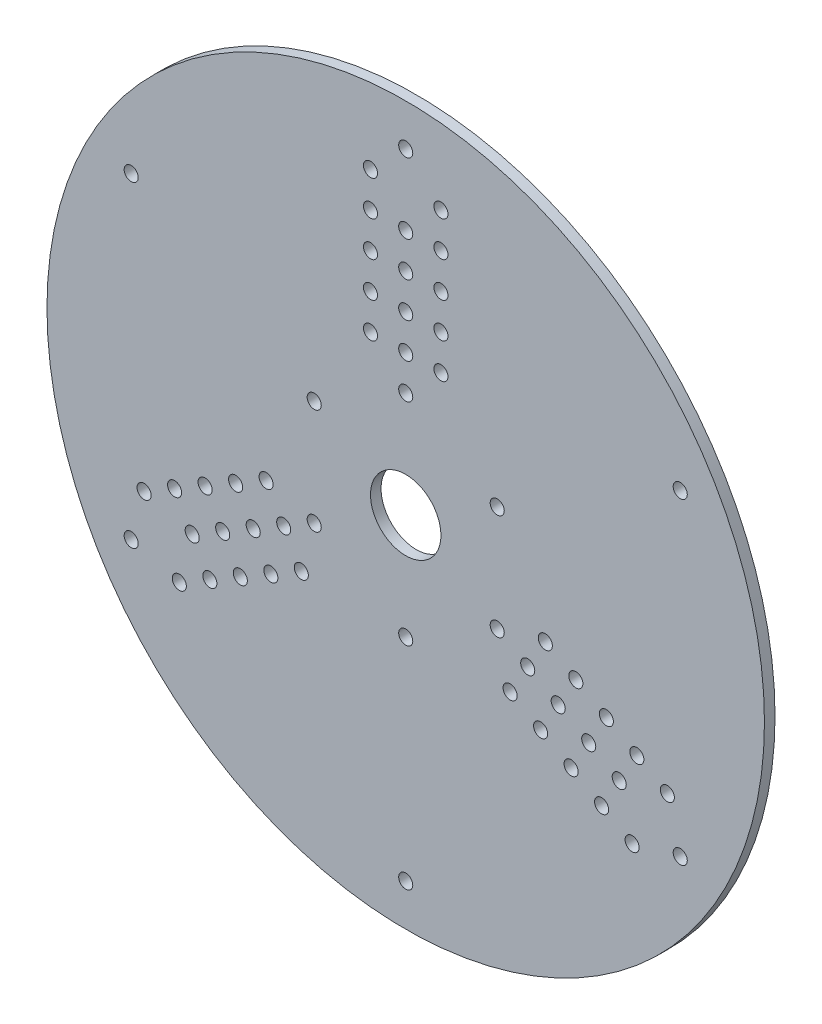
from build123d import *

# Parameters (mm, degrees)
SKETCH1_R           = 101.859163579
SKETCH1_R_2         = 2
SKETCH1_R_3         = 10
BOSS_EXTRUDE1_DEPTH = 3


with BuildPart() as part:
    # Sketch1 → Boss-Extrude1 (new body)
    with BuildSketch(Plane.XY):
        Circle(SKETCH1_R)
        with Locations((0, 30)):
            Circle(SKETCH1_R_2, mode=Mode.SUBTRACT)
        with Locations((-10, 50)):
            Circle(SKETCH1_R_2, mode=Mode.SUBTRACT)
        with Locations((0, 40)):
            Circle(SKETCH1_R_2, mode=Mode.SUBTRACT)
        with Locations((10, 50)):
            Circle(SKETCH1_R_2, mode=Mode.SUBTRACT)
        with Locations((-10, 60)):
            Circle(SKETCH1_R_2, mode=Mode.SUBTRACT)
        with Locations((-10, 40)):
            Circle(SKETCH1_R_2, mode=Mode.SUBTRACT)
        with Locations((10, 40)):
            Circle(SKETCH1_R_2, mode=Mode.SUBTRACT)
        with Locations((0, 50)):
            Circle(SKETCH1_R_2, mode=Mode.SUBTRACT)
        with Locations((10, 60)):
            Circle(SKETCH1_R_2, mode=Mode.SUBTRACT)
        with Locations((-10, 70)):
            Circle(SKETCH1_R_2, mode=Mode.SUBTRACT)
        with Locations((0, 60)):
            Circle(SKETCH1_R_2, mode=Mode.SUBTRACT)
        with Locations((10, 70)):
            Circle(SKETCH1_R_2, mode=Mode.SUBTRACT)
        with Locations((-10, 80)):
            Circle(SKETCH1_R_2, mode=Mode.SUBTRACT)
        with Locations((0, 70)):
            Circle(SKETCH1_R_2, mode=Mode.SUBTRACT)
        with Locations((10, 80)):
            Circle(SKETCH1_R_2, mode=Mode.SUBTRACT)
        with Locations((25.980762114, -15)):
            Circle(SKETCH1_R_2, mode=Mode.SUBTRACT)
        with Locations((48.301270189, -16.339745962)):
            Circle(SKETCH1_R_2, mode=Mode.SUBTRACT)
        with Locations((34.641016151, -20)):
            Circle(SKETCH1_R_2, mode=Mode.SUBTRACT)
        with Locations((38.301270189, -33.660254038)):
            Circle(SKETCH1_R_2, mode=Mode.SUBTRACT)
        with Locations((56.961524227, -21.339745962)):
            Circle(SKETCH1_R_2, mode=Mode.SUBTRACT)
        with Locations((39.641016151, -11.339745962)):
            Circle(SKETCH1_R_2, mode=Mode.SUBTRACT)
        with Locations((29.641016151, -28.660254038)):
            Circle(SKETCH1_R_2, mode=Mode.SUBTRACT)
        with Locations((43.301270189, -25)):
            Circle(SKETCH1_R_2, mode=Mode.SUBTRACT)
        with Locations((46.961524227, -38.660254038)):
            Circle(SKETCH1_R_2, mode=Mode.SUBTRACT)
        with Locations((65.621778265, -26.339745962)):
            Circle(SKETCH1_R_2, mode=Mode.SUBTRACT)
        with Locations((51.961524227, -30)):
            Circle(SKETCH1_R_2, mode=Mode.SUBTRACT)
        with Locations((55.621778265, -43.660254038)):
            Circle(SKETCH1_R_2, mode=Mode.SUBTRACT)
        with Locations((74.282032303, -31.339745962)):
            Circle(SKETCH1_R_2, mode=Mode.SUBTRACT)
        with Locations((60.621778265, -35)):
            Circle(SKETCH1_R_2, mode=Mode.SUBTRACT)
        with Locations((64.282032303, -48.660254038)):
            Circle(SKETCH1_R_2, mode=Mode.SUBTRACT)
        with Locations((-25.980762114, -15)):
            Circle(SKETCH1_R_2, mode=Mode.SUBTRACT)
        with Locations((-38.301270189, -33.660254038)):
            Circle(SKETCH1_R_2, mode=Mode.SUBTRACT)
        with Locations((-34.641016151, -20)):
            Circle(SKETCH1_R_2, mode=Mode.SUBTRACT)
        with Locations((-48.301270189, -16.339745962)):
            Circle(SKETCH1_R_2, mode=Mode.SUBTRACT)
        with Locations((-46.961524227, -38.660254038)):
            Circle(SKETCH1_R_2, mode=Mode.SUBTRACT)
        with Locations((-29.641016151, -28.660254038)):
            Circle(SKETCH1_R_2, mode=Mode.SUBTRACT)
        with Locations((-39.641016151, -11.339745962)):
            Circle(SKETCH1_R_2, mode=Mode.SUBTRACT)
        with Locations((-43.301270189, -25)):
            Circle(SKETCH1_R_2, mode=Mode.SUBTRACT)
        with Locations((-56.961524227, -21.339745962)):
            Circle(SKETCH1_R_2, mode=Mode.SUBTRACT)
        with Locations((-55.621778265, -43.660254038)):
            Circle(SKETCH1_R_2, mode=Mode.SUBTRACT)
        with Locations((-51.961524227, -30)):
            Circle(SKETCH1_R_2, mode=Mode.SUBTRACT)
        with Locations((-65.621778265, -26.339745962)):
            Circle(SKETCH1_R_2, mode=Mode.SUBTRACT)
        with Locations((-64.282032303, -48.660254038)):
            Circle(SKETCH1_R_2, mode=Mode.SUBTRACT)
        with Locations((-60.621778265, -35)):
            Circle(SKETCH1_R_2, mode=Mode.SUBTRACT)
        with Locations((-74.282032303, -31.339745962)):
            Circle(SKETCH1_R_2, mode=Mode.SUBTRACT)
        with Locations((77.942286341, 45)):
            Circle(SKETCH1_R_2, mode=Mode.SUBTRACT)
        with Locations((77.942286341, -45)):
            Circle(SKETCH1_R_2, mode=Mode.SUBTRACT)
        with Locations((0, -90)):
            Circle(SKETCH1_R_2, mode=Mode.SUBTRACT)
        with Locations((-77.942286341, -45)):
            Circle(SKETCH1_R_2, mode=Mode.SUBTRACT)
        with Locations((-77.942286341, 45)):
            Circle(SKETCH1_R_2, mode=Mode.SUBTRACT)
        with Locations((0, 90)):
            Circle(SKETCH1_R_2, mode=Mode.SUBTRACT)
        Circle(SKETCH1_R_3, mode=Mode.SUBTRACT)
        with Locations((25.980762114, 15)):
            Circle(SKETCH1_R_2, mode=Mode.SUBTRACT)
        with Locations((0, -30)):
            Circle(SKETCH1_R_2, mode=Mode.SUBTRACT)
        with Locations((-25.980762114, 15)):
            Circle(SKETCH1_R_2, mode=Mode.SUBTRACT)
    extrude(amount=BOSS_EXTRUDE1_DEPTH)


solid = part.part
